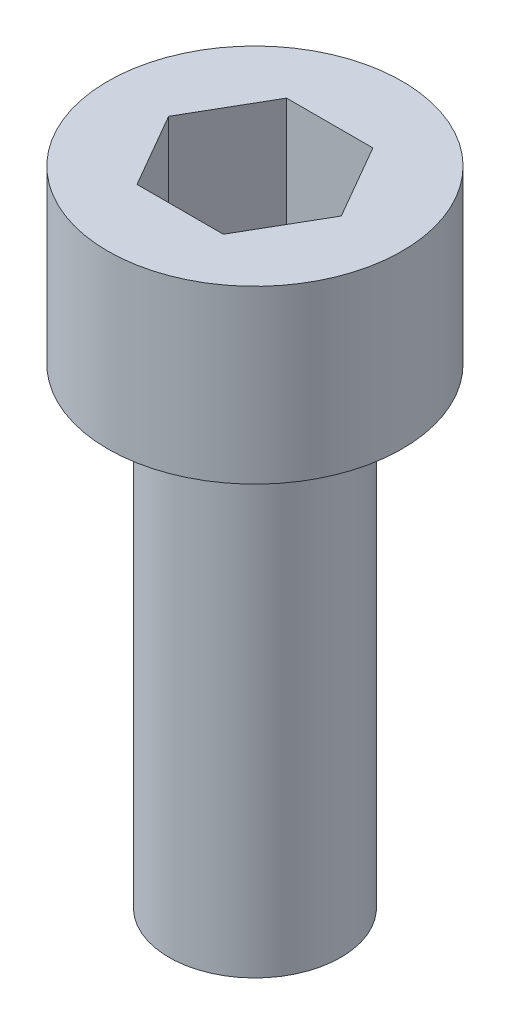
from build123d import *

# Parameters (mm, degrees)
SKETCH1_R           = 5
BOSS_EXTRUDE1_DEPTH = 5.82
SKETCH2_R           = 2.92
BOSS_EXTRUDE2_DEPTH = 16
CUT_EXTRUDE1_DEPTH  = 4.23


with BuildPart() as part:
    # Sketch1 → Boss-Extrude1 (new body)
    with BuildSketch(Plane(origin=(0, 0, 0), x_dir=(1, 0, 0), z_dir=(0, 1, 0))):
        Circle(SKETCH1_R)
    extrude(amount=BOSS_EXTRUDE1_DEPTH)

    # Sketch2 → Boss-Extrude2 (add)
    with BuildSketch(Plane.XZ):
        Circle(SKETCH2_R)
    extrude(amount=BOSS_EXTRUDE2_DEPTH)

    # Sketch3 → Cut-Extrude1 (cut)
    with BuildSketch(Plane(origin=(0, 5.82, 0), x_dir=(1, 0, 0), z_dir=(0, 1, 0))):
        Polygon((2.932939367, 0), (1.466469684, 2.54), (-1.466469684, 2.54), (-2.932939367, 0), (-1.466469684, -2.54), (1.466469684, -2.54), align=None)
    extrude(amount=-CUT_EXTRUDE1_DEPTH, mode=Mode.SUBTRACT)


solid = part.part
